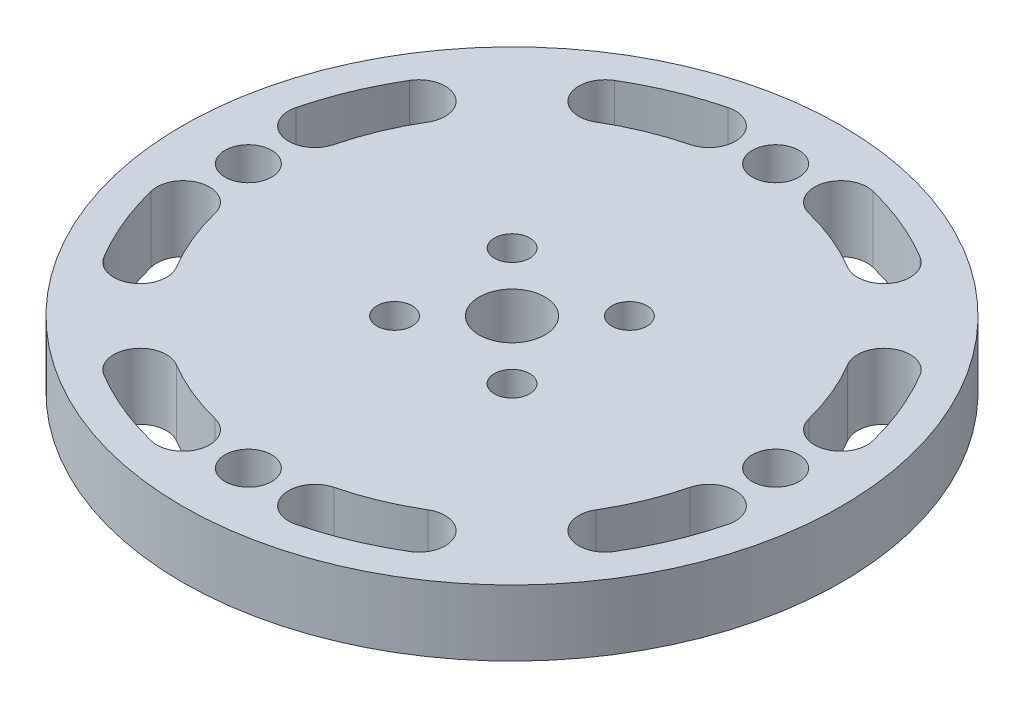
from build123d import *

# Parameters (mm, degrees)
SKETCH1_R           = 31.75
BOSS_EXTRUDE1_DEPTH = 6.35
SKETCH2_R           = 3.175
SKETCH2_R_2         = 1.7
CUT_EXTRUDE1_DEPTH  = 7.35
CUT_EXTRUDE2_DEPTH  = 7.35
SKETCH4_R           = 2.2479
CUT_EXTRUDE3_DEPTH  = 7.35


with BuildPart() as part:
    # Sketch1 → Boss-Extrude1 (new body)
    with BuildSketch(Plane(origin=(0, 0, 0), x_dir=(1, 0, 0), z_dir=(0, 1, 0))):
        Circle(SKETCH1_R)
    extrude(amount=BOSS_EXTRUDE1_DEPTH)

    # Sketch2 → Cut-Extrude1 (cut, through all)
    with BuildSketch(Plane(origin=(0, 6.35, 0), x_dir=(1, 0, 0), z_dir=(0, 1, 0))):
        Circle(SKETCH2_R)
        with Locations((-5.655, 5.662415783)):
            Circle(SKETCH2_R_2)
        with Locations((5.655, 5.655)):
            Circle(SKETCH2_R_2)
        with Locations((5.655, -5.655)):
            Circle(SKETCH2_R_2)
        with Locations((-5.662415783, -5.655)):
            Circle(SKETCH2_R_2)
    extrude(amount=-CUT_EXTRUDE1_DEPTH, mode=Mode.SUBTRACT)

    # Sketch3 → Cut-Extrude2 (cut, through all)
    with BuildSketch(Plane(origin=(0, 6.35, 0), x_dir=(1, 0, 0), z_dir=(0, 1, 0))):
        with BuildLine():
            ThreePointArc((-6.96754053, 27.798227251), (-10.966989178, 26.476654013), (-14.729519838, 24.583110151))
            ThreePointArc((-14.729519838, 24.583110151), (-15.60285403, 21.098789932), (-12.118533811, 20.22545574))
            ThreePointArc((-12.118533811, 20.22545574), (-9.022957342, 21.783345987), (-5.73245947, 22.870654342))
            ThreePointArc((-5.73245947, 22.870654342), (-3.886213545, 25.951981326), (-6.96754053, 27.798227251))
        make_face()
        with BuildLine():
            ThreePointArc((-27.798227251, 6.96754053), (-26.476654013, 10.966989178), (-24.583110151, 14.729519838))
            ThreePointArc((-24.583110151, 14.729519838), (-21.098789932, 15.60285403), (-20.22545574, 12.118533811))
            ThreePointArc((-20.22545574, 12.118533811), (-21.783345987, 9.022957342), (-22.870654342, 5.73245947))
            ThreePointArc((-22.870654342, 5.73245947), (-25.951981326, 3.886213545), (-27.798227251, 6.96754053))
        make_face()
        with BuildLine():
            ThreePointArc((-27.798227251, -6.96754053), (-26.476654013, -10.966989178), (-24.583110151, -14.729519838))
            ThreePointArc((-24.583110151, -14.729519838), (-21.098789932, -15.60285403), (-20.22545574, -12.118533811))
            ThreePointArc((-20.22545574, -12.118533811), (-21.783345987, -9.022957342), (-22.870654342, -5.73245947))
            ThreePointArc((-22.870654342, -5.73245947), (-25.951981326, -3.886213545), (-27.798227251, -6.96754053))
        make_face()
        with BuildLine():
            ThreePointArc((-6.96754053, -27.798227251), (-10.966989178, -26.476654013), (-14.729519838, -24.583110151))
            ThreePointArc((-14.729519838, -24.583110151), (-15.60285403, -21.098789932), (-12.118533811, -20.22545574))
            ThreePointArc((-12.118533811, -20.22545574), (-9.022957342, -21.783345987), (-5.73245947, -22.870654342))
            ThreePointArc((-5.73245947, -22.870654342), (-3.886213545, -25.951981326), (-6.96754053, -27.798227251))
        make_face()
        with BuildLine():
            ThreePointArc((6.96754053, -27.798227251), (10.966989178, -26.476654013), (14.729519838, -24.583110151))
            ThreePointArc((14.729519838, -24.583110151), (15.60285403, -21.098789932), (12.118533811, -20.22545574))
            ThreePointArc((12.118533811, -20.22545574), (9.022957342, -21.783345987), (5.73245947, -22.870654342))
            ThreePointArc((5.73245947, -22.870654342), (3.886213545, -25.951981326), (6.96754053, -27.798227251))
        make_face()
        with BuildLine():
            ThreePointArc((27.798227251, -6.96754053), (26.476654013, -10.966989178), (24.583110151, -14.729519838))
            ThreePointArc((24.583110151, -14.729519838), (21.098789932, -15.60285403), (20.22545574, -12.118533811))
            ThreePointArc((20.22545574, -12.118533811), (21.783345987, -9.022957342), (22.870654342, -5.73245947))
            ThreePointArc((22.870654342, -5.73245947), (25.951981326, -3.886213545), (27.798227251, -6.96754053))
        make_face()
        with BuildLine():
            ThreePointArc((27.798227251, 6.96754053), (26.476654013, 10.966989178), (24.583110151, 14.729519838))
            ThreePointArc((24.583110151, 14.729519838), (21.098789932, 15.60285403), (20.22545574, 12.118533811))
            ThreePointArc((20.22545574, 12.118533811), (21.783345987, 9.022957342), (22.870654342, 5.73245947))
            ThreePointArc((22.870654342, 5.73245947), (25.951981326, 3.886213545), (27.798227251, 6.96754053))
        make_face()
        with BuildLine():
            ThreePointArc((6.96754053, 27.798227251), (10.966989178, 26.476654013), (14.729519838, 24.583110151))
            ThreePointArc((14.729519838, 24.583110151), (15.60285403, 21.098789932), (12.118533811, 20.22545574))
            ThreePointArc((12.118533811, 20.22545574), (9.022957342, 21.783345987), (5.73245947, 22.870654342))
            ThreePointArc((5.73245947, 22.870654342), (3.886213545, 25.951981326), (6.96754053, 27.798227251))
        make_face()
    extrude(amount=-CUT_EXTRUDE2_DEPTH, mode=Mode.SUBTRACT)

    # Sketch4 → Cut-Extrude3 (cut, through all)
    with BuildSketch(Plane(origin=(0, 6.35, 0), x_dir=(1, 0, 0), z_dir=(0, 1, 0))):
        with Locations((0, -25.4)):
            Circle(SKETCH4_R)
        with Locations((25.4, 0)):
            Circle(SKETCH4_R)
        with Locations((-25.4, 0)):
            Circle(SKETCH4_R)
        with Locations((0, 25.4)):
            Circle(SKETCH4_R)
    extrude(amount=-CUT_EXTRUDE3_DEPTH, mode=Mode.SUBTRACT)


solid = part.part
